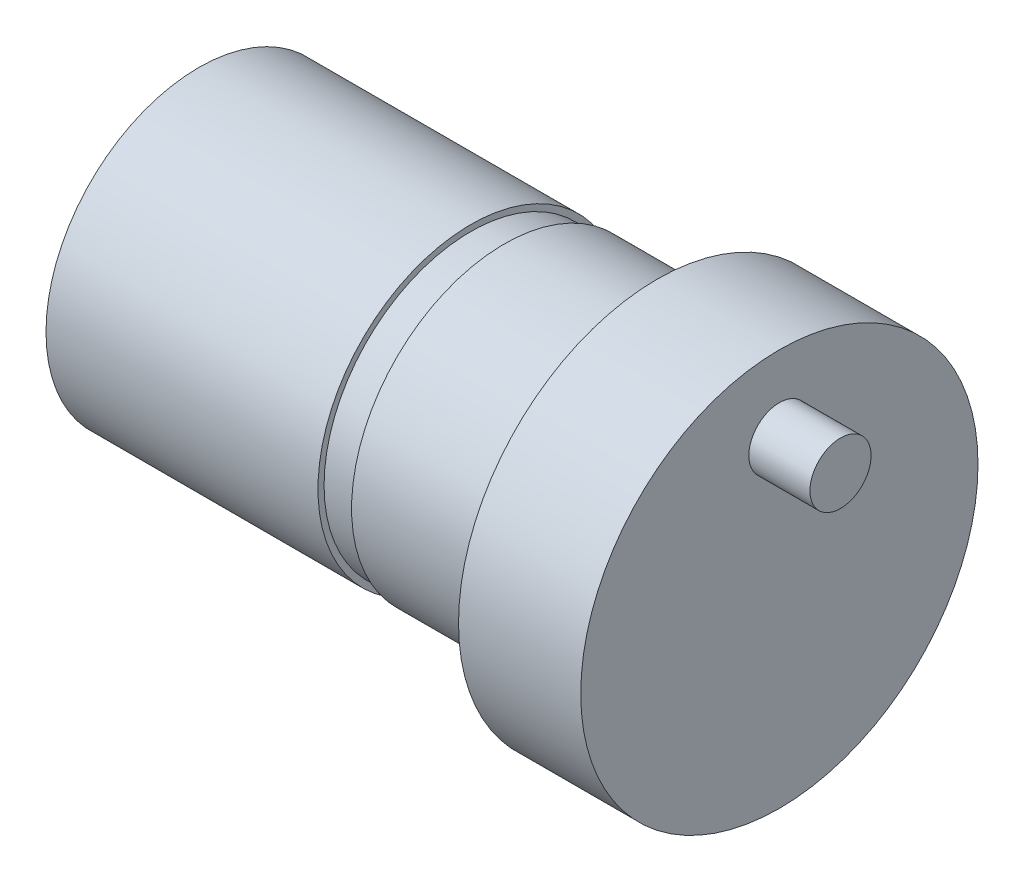
from build123d import *

# Parameters (mm, degrees)
SKETCH1_R           = 6.5
BOSS_EXTRUDE1_DEPTH = 4
SKETCH2_R           = 5
BOSS_EXTRUDE2_DEPTH = 15
SKETCH3_R           = 1
BOSS_EXTRUDE3_DEPTH = 2
SKETCH4_W           = 1.1
SKETCH4_H           = 0.2


with BuildPart() as part:
    # Sketch1 → Boss-Extrude1 (new body)
    with BuildSketch(Plane(origin=(0, 0, 0), x_dir=(0, 0, -1), z_dir=(1, 0, 0))):
        Circle(SKETCH1_R)
    extrude(amount=BOSS_EXTRUDE1_DEPTH)

    # Sketch2 → Boss-Extrude2 (add)
    with BuildSketch(Plane.ZY):
        Circle(SKETCH2_R)
    extrude(amount=BOSS_EXTRUDE2_DEPTH)

    # Sketch3 → Boss-Extrude3 (add)
    with BuildSketch(Plane(origin=(4, 0, 0), x_dir=(0, 0, -1), z_dir=(1, 0, 0))):
        with Locations((0, 4)):
            Circle(SKETCH3_R)
    extrude(amount=BOSS_EXTRUDE3_DEPTH)

    # Sketch4 → Cut-Revolve1 (revolve, cut)
    with BuildSketch(Plane.XY):
        with Locations((-5.55, 4.9)):
            Rectangle(SKETCH4_W, SKETCH4_H)
    revolve(axis=Axis((-1.178470482, 0, 0), (-1, 0, 0)), mode=Mode.SUBTRACT)


solid = part.part
